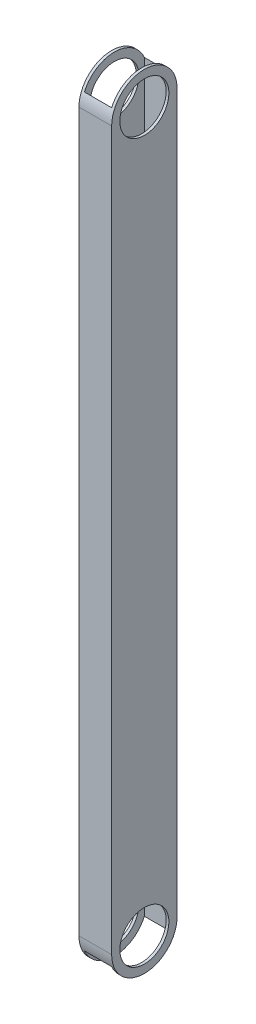
from build123d import *

# Parameters (mm, degrees)
SKETCH2_W           = 19.05
SKETCH2_H           = 38.1
SKETCH2_W_2         = 15.875
SKETCH2_H_2         = 34.925
EXTRUDE_THIN1_DEPTH = 456.184
SKETCH3_R           = 14.2875
CUT_EXTRUDE1_DEPTH  = 20.05


with BuildPart() as part:
    # Sketch2 → Extrude-Thin1 (new body)
    with BuildSketch(Plane(origin=(0, 0, 0), x_dir=(1, 0, 0), z_dir=(0, 1, 0))):
        with Locations((9.525, 19.05)):
            Rectangle(SKETCH2_W, SKETCH2_H)
        with Locations((9.525, 19.05)):
            Rectangle(SKETCH2_W_2, SKETCH2_H_2, mode=Mode.SUBTRACT)
    extrude(amount=EXTRUDE_THIN1_DEPTH)

    # Sketch3 → Cut-Extrude1 (cut, through all)
    with BuildSketch(Plane.ZY):
        with Locations((-19.05, 19.05)):
            Circle(SKETCH3_R)
        with BuildLine():
            ThreePointArc((-19.05, 0), (-32.520384182, 5.579615818), (-38.1, 19.05))
            Line((-38.1, 19.05), (-38.1, 0))
            Line((-38.1, 0), (-19.05, 0))
        make_face()
        with BuildLine():
            ThreePointArc((0, 19.05), (-5.579615818, 5.579615818), (-19.05, 0))
            Line((-19.05, 0), (0, 0))
            Line((0, 0), (0, 19.05))
        make_face()
        with Locations((-19.05, 437.134)):
            Circle(SKETCH3_R)
        with BuildLine():
            Line((-38.1, 456.184), (-38.1, 437.134))
            ThreePointArc((-38.1, 437.134), (-32.520384182, 450.604384182), (-19.05, 456.184))
            Line((-19.05, 456.184), (-38.1, 456.184))
        make_face()
        with BuildLine():
            Line((0, 456.184), (-19.05, 456.184))
            ThreePointArc((-19.05, 456.184), (-5.579615818, 450.604384182), (0, 437.134))
            Line((0, 437.134), (0, 456.184))
        make_face()
    extrude(amount=-CUT_EXTRUDE1_DEPTH, mode=Mode.SUBTRACT)


solid = part.part
